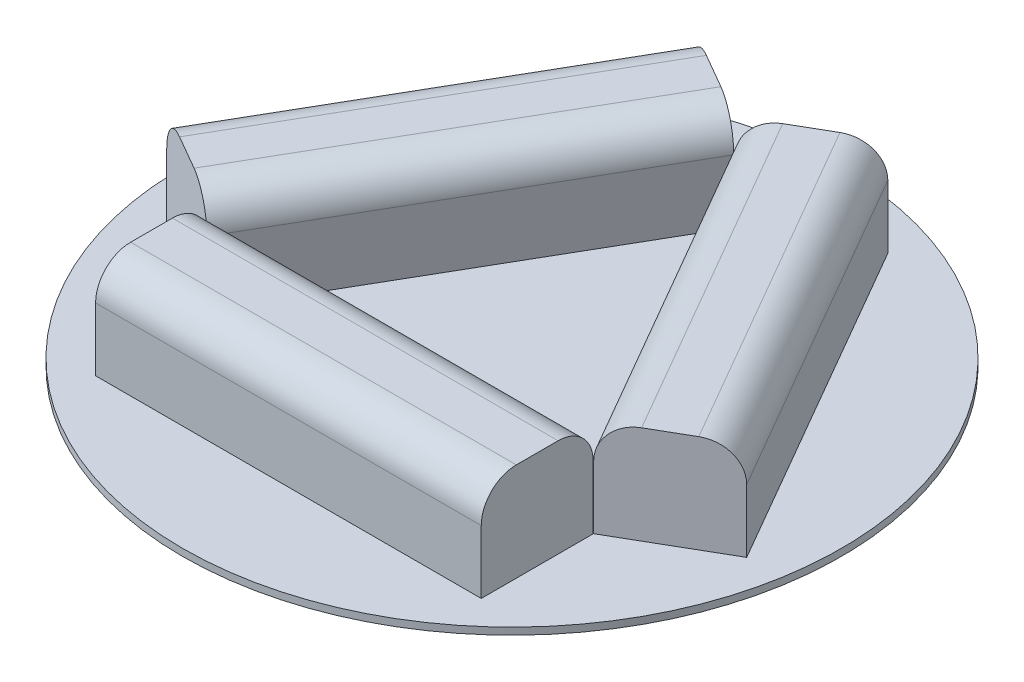
from build123d import *

# Parameters (mm, degrees)
BOSS_EXTRUDE1_DEPTH     = 15
SKETCH1_W               = 55
SKETCH1_H               = 15.959882119
BOSS_EXTRUDE1_2_DEPTH   = 15
BOSS_EXTRUDE1_3_DEPTH   = 15
FILLET1_R               = 5
FILLET2_R               = 5
FILLET3_R               = 5
FILLET4_R               = 5
FILLET5_R               = 5
FILLET6_R               = 5
SHELL1_T                = -1
SHELL2_T                = -1
SHELL3_T                = -1
FILLET7_R               = 3
FILLET8_R               = 3
FILLET9_R               = 3
FILLET10_R              = 3
FILLET11_R              = 3
FILLET12_R              = 3
SKETCH2_R               = 47
BOSS_EXTRUDE2_DEPTH     = 1
CUT_EXTRUDE1_DEPTH      = 1
CUT_EXTRUDE1_DEPTH_BACK = 13


with BuildPart() as part:
    # Sketch1 → Boss-Extrude1 (new body)
    with BuildSketch(Plane(origin=(0, 0, 0), x_dir=(1, 0, 0), z_dir=(0, 1, 0))):
        Polygon((0.023694735, 0.013680161), (13.856406461, 8), (41.356406461, -39.631397208), (27.523694735, -47.617717047), align=None)
    extrude(amount=BOSS_EXTRUDE1_DEPTH)

    # Fillet3
    fillet3_edges = [part.edges().sort_by_distance(p)[0] for p in [
        (27.606406461, 15, 15.815698604),
    ]]
    fillet(fillet3_edges, radius=FILLET3_R)

    # Fillet4
    fillet4_edges = [part.edges().sort_by_distance(p)[0] for p in [
        (13.773694735, 15, 23.802018443),
    ]]
    fillet(fillet4_edges, radius=FILLET4_R)

    # Shell3
    shell3_openings = [part.faces().sort_by_distance(p)[0] for p in [
        (20.690050598, 0, 19.808858523),
    ]]
    offset(amount=SHELL3_T, openings=shell3_openings, kind=Kind.INTERSECTION)

    # Fillet9
    fillet9_edges = [part.edges().sort_by_distance(p)[0] for p in [
        (2.404332011, 12.828427125, -0.233441195),
        (12.475769184, 12.828427125, -6.048188159),
        (13.490381057, 5, -6.633974596),
        (1.389720138, 5, 0.352345242),
        (7.440050598, 14, -3.140814677),
    ]]
    fillet(fillet9_edges, radius=FILLET9_R)

    # Fillet12
    fillet12_edges = [part.edges().sort_by_distance(p)[0] for p in [
        (39.990381057, 5, 39.265371804),
        (28.904332011, 12.828427125, 45.665905205),
        (27.889720138, 5, 46.251691643),
        (38.975769184, 12.828427125, 39.851158242),
        (33.940050598, 14, 42.758531724),
    ]]
    fillet(fillet12_edges, radius=FILLET12_R)



with BuildPart() as body_2:
    # Sketch1 → Boss-Extrude1 2 (new body)
    with BuildSketch(Plane(origin=(0, 0, 0), x_dir=(1, 0, 0), z_dir=(0, 1, 0))):
        with Locations((0, -55.651456149)):
            Rectangle(SKETCH1_W, SKETCH1_H)
    extrude(amount=BOSS_EXTRUDE1_2_DEPTH)

    # Fillet1
    fillet1_edges = [body_2.edges().sort_by_distance(p)[0] for p in [
        (0, 15, 63.631397208),
    ]]
    fillet(fillet1_edges, radius=FILLET1_R)

    # Fillet2
    fillet2_edges = [body_2.edges().sort_by_distance(p)[0] for p in [
        (0, 15, 47.671515089),
    ]]
    fillet(fillet2_edges, radius=FILLET2_R)

    # Shell2
    shell2_openings = [body_2.faces().sort_by_distance(p)[0] for p in [
        (0, 0, 55.651456149),
    ]]
    offset(amount=SHELL2_T, openings=shell2_openings, kind=Kind.INTERSECTION)

    # Fillet10
    fillet10_edges = [body_2.edges().sort_by_distance(p)[0] for p in [
        (-26.5, 5, 62.631397208),
        (-26.5, 12.828427125, 49.843087964),
        (-26.5, 5, 48.671515089),
        (-26.5, 12.828427125, 61.459824333),
        (-26.5, 14, 55.651456149),
    ]]
    fillet(fillet10_edges, radius=FILLET10_R)

    # Fillet11
    fillet11_edges = [body_2.edges().sort_by_distance(p)[0] for p in [
        (26.5, 12.828427125, 49.843087964),
        (26.5, 12.828427125, 61.459824333),
        (26.5, 5, 62.631397208),
        (26.5, 5, 48.671515089),
        (26.5, 14, 55.651456149),
    ]]
    fillet(fillet11_edges, radius=FILLET11_R)


with BuildPart() as body_3:
    # Sketch1 → Boss-Extrude1 3 (new body)
    with BuildSketch(Plane(origin=(0, 0, 0), x_dir=(1, 0, 0), z_dir=(0, 1, 0))):
        Polygon((-27.789098516, -47.464486102), (-41.356406461, -39.631397208), (-13.856406461, 8), (-0.289098516, 0.166911106), align=None)
    extrude(amount=BOSS_EXTRUDE1_3_DEPTH)

    # Fillet5
    fillet5_edges = [body_3.edges().sort_by_distance(p)[0] for p in [
        (-14.039098516, 15, 23.648787498),
    ]]
    fillet(fillet5_edges, radius=FILLET5_R)

    # Fillet6
    fillet6_edges = [body_3.edges().sort_by_distance(p)[0] for p in [
        (-27.606406461, 15, 15.815698604),
    ]]
    fillet(fillet6_edges, radius=FILLET6_R)

    # Shell1
    shell1_openings = [body_3.faces().sort_by_distance(p)[0] for p in [
        (-20.822752488, 0, 19.732243051),
    ]]
    offset(amount=SHELL1_T, openings=shell1_openings, kind=Kind.INTERSECTION)

    # Fillet7
    fillet7_edges = [body_3.edges().sort_by_distance(p)[0] for p in [
        (-28.155123919, 5, 46.098460699),
        (-38.975769184, 12.828427125, 39.851158242),
        (-39.990381057, 5, 39.265371804),
        (-29.169735792, 12.828427125, 45.512674261),
        (-34.072752488, 14, 42.681916251),
    ]]
    fillet(fillet7_edges, radius=FILLET7_R)

    # Fillet8
    fillet8_edges = [body_3.edges().sort_by_distance(p)[0] for p in [
        (-12.475769184, 12.828427125, -6.048188159),
        (-2.669735792, 12.828427125, -0.38667214),
        (-1.655123919, 5, 0.199114298),
        (-13.490381057, 5, -6.633974596),
        (-7.572752488, 14, -3.217430149),
    ]]
    fillet(fillet8_edges, radius=FILLET8_R)


with BuildPart() as part_1:
    add(part.part)

    add(body_2.part)  # Boss-Extrude2 merges body 2

    add(body_3.part)  # Boss-Extrude2 merges body 3
    # Sketch2 → Boss-Extrude2 (add)
    with BuildSketch(Plane(origin=(0, 0, 0), x_dir=(1, 0, 0), z_dir=(0, 1, 0))):
        with Locations((0, -31.745023024)):
            Circle(SKETCH2_R)
    extrude(amount=BOSS_EXTRUDE2_DEPTH)

    # Sketch3 → Cut-Extrude1 (cut, two sides)
    with BuildSketch(Plane(origin=(0, 0, 0), x_dir=(1, 0, 0), z_dir=(0, 1, 0))) as cut_extrude1_sk:
        with BuildLine():
            Line((3.987006883, 1.141166124), (10.886295934, 5.136526307))
            ThreePointArc((10.886295934, 5.136526307), (13.164256292, 5.43870151), (14.98777262, 4.04041633))
            Line((14.98777262, 4.04041633), (37.191342951, -34.417295593))
            ThreePointArc((37.191342951, -34.417295593), (37.491044219, -36.693752728), (36.09326674, -38.515371804))
            Line((36.09326674, -38.515371804), (29.188758244, -42.501691643))
            ThreePointArc((29.188758244, -42.501691643), (26.912301109, -42.801392911), (25.090682033, -41.403615432))
            Line((25.090682033, -41.403615432), (2.892331147, -2.954943853))
            ThreePointArc((2.892331147, -2.954943853), (2.592122178, -0.68038397), (3.987006883, 1.141166124))
        make_face()
        with BuildLine():
            Line((-23.5, -48.671515089), (23.5, -48.671515089))
            ThreePointArc((23.5, -48.671515089), (25.621320344, -49.550194746), (26.5, -51.671515089))
            Line((26.5, -51.671515089), (26.5, -59.631397208))
            ThreePointArc((26.5, -59.631397208), (25.621320344, -61.752717552), (23.5, -62.631397208))
            Line((23.5, -62.631397208), (-23.5, -62.631397208))
            ThreePointArc((-23.5, -62.631397208), (-25.621320344, -61.752717552), (-26.5, -59.631397208))
            Line((-26.5, -59.631397208), (-26.5, -51.671515089))
            ThreePointArc((-26.5, -51.671515089), (-25.621320344, -49.550194746), (-23.5, -48.671515089))
        make_face()
        with BuildLine():
            Line((-26.655123919, -43.500384487), (-3.155123919, -2.797190509))
            ThreePointArc((-3.155123919, -2.797190509), (-2.855422652, -0.520733374), (-4.253200131, 1.300885702))
            Line((-4.253200131, 1.300885702), (-10.892304845, 5.133974596))
            ThreePointArc((-10.892304845, 5.133974596), (-13.168761981, 5.433675864), (-14.990381057, 4.035898385))
            Line((-14.990381057, 4.035898385), (-38.490381057, -36.667295593))
            ThreePointArc((-38.490381057, -36.667295593), (-38.790082324, -38.943752728), (-37.392304845, -40.765371804))
            Line((-37.392304845, -40.765371804), (-30.753200131, -44.598460699))
            ThreePointArc((-30.753200131, -44.598460699), (-28.476742995, -44.898161966), (-26.655123919, -43.500384487))
        make_face()
    extrude(amount=CUT_EXTRUDE1_DEPTH, mode=Mode.SUBTRACT)
    extrude(cut_extrude1_sk.sketch, amount=-CUT_EXTRUDE1_DEPTH_BACK, mode=Mode.SUBTRACT)


solid = part_1.part
